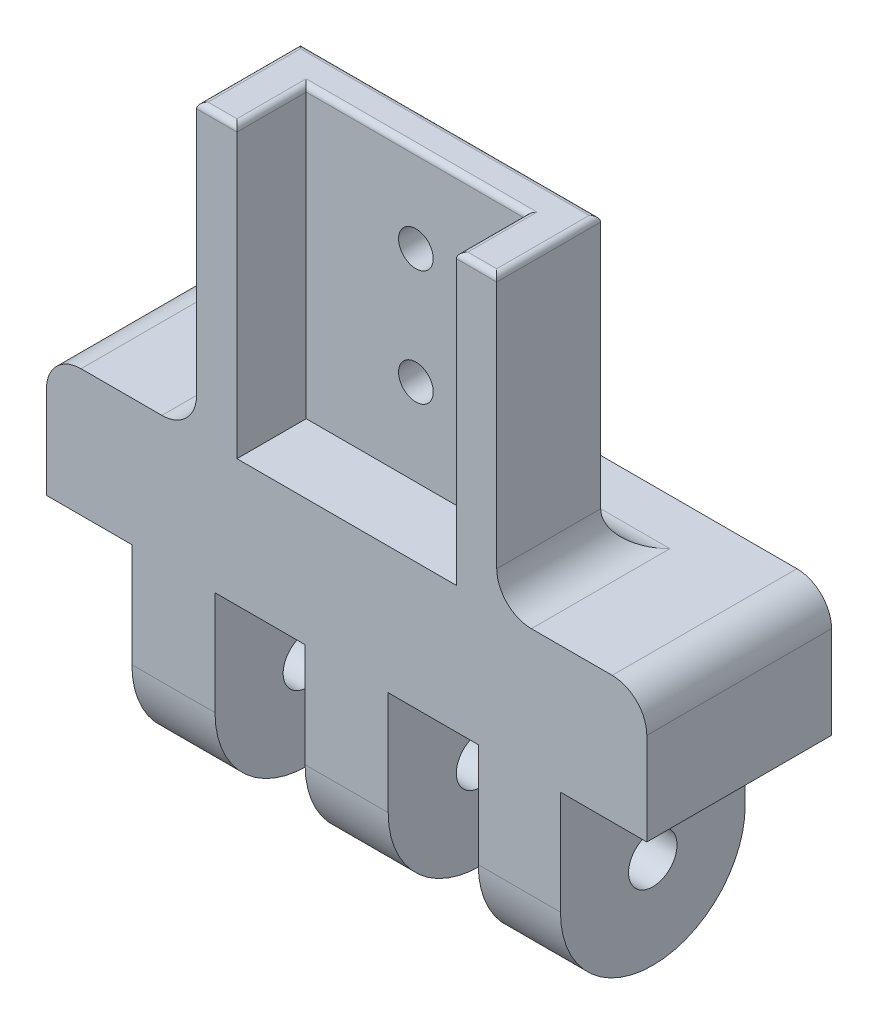
from build123d import *

# Parameters (mm, degrees)
SKETCH2_R           = 2.1
BOSS_EXTRUDE1_DEPTH = 26
SKETCH3_W           = 7.4
SKETCH3_H           = 18
SKETCH3_W_2         = 7.8
SKETCH3_W_3         = 7.481047655
CUT_EXTRUDE1_DEPTH  = 17
SKETCH4_W           = 26
SKETCH4_H           = 9
BOSS_EXTRUDE2_DEPTH = 25
SKETCH5_W           = 19
SKETCH5_H           = 6
CUT_EXTRUDE2_DEPTH  = 25
FILLET1_R           = 3
FILLET2_R           = 3
FILLET3_R           = 0.5
SKETCH6_R           = 1.5
CUT_EXTRUDE3_DEPTH  = 12.5


with BuildPart() as part:
    # Sketch2 → Boss-Extrude1 (new body, symmetric)
    with BuildSketch(Plane(origin=(0, 0, 0), x_dir=(0, 0, -1), z_dir=(1, 0, 0))):
        with BuildLine():
            Line((-8, 0), (-8, 20))
            Line((-8, 20), (8, 20))
            Line((8, 20), (8, 0))
            ThreePointArc((8, 0), (0, -8), (-8, 0))
        make_face()
        Circle(SKETCH2_R, mode=Mode.SUBTRACT)
    extrude(amount=BOSS_EXTRUDE1_DEPTH, both=True)

    # Sketch3 → Cut-Extrude1 (cut, through all)
    with BuildSketch(Plane.XY.offset(8)):
        with Locations((-22.3, 0)):
            Rectangle(SKETCH3_W, SKETCH3_H)
        with Locations((-7.5, 0)):
            Rectangle(SKETCH3_W_2, SKETCH3_H)
        with Locations((7.5, 0)):
            Rectangle(SKETCH3_W_2, SKETCH3_H)
        with Locations((22.259476173, 0)):
            Rectangle(SKETCH3_W_3, SKETCH3_H)
    extrude(amount=-CUT_EXTRUDE1_DEPTH, mode=Mode.SUBTRACT)

    # Sketch4 → Boss-Extrude2 (add)
    with BuildSketch(Plane(origin=(0, 20, 0), x_dir=(1, 0, 0), z_dir=(0, 1, 0))):
        with Locations((0, -3.5)):
            Rectangle(SKETCH4_W, SKETCH4_H)
    extrude(amount=BOSS_EXTRUDE2_DEPTH)

    # Sketch5 → Cut-Extrude2 (cut)
    with BuildSketch(Plane(origin=(0, 45, 0), x_dir=(1, 0, 0), z_dir=(0, 1, 0))):
        with Locations((0, -5)):
            Rectangle(SKETCH5_W, SKETCH5_H)
    extrude(amount=-CUT_EXTRUDE2_DEPTH, mode=Mode.SUBTRACT)

    # Fillet1
    fillet1_edges = [part.edges().sort_by_distance(p)[0] for p in [
        (-13, 20, 3.5),
        (13, 20, 3.5),
        (0, 20, -1),
    ]]
    fillet(fillet1_edges, radius=FILLET1_R)

    # Fillet2
    fillet2_edges = [part.edges().sort_by_distance(p)[0] for p in [
        (26, 20, 0),
        (-26, 20, 0),
    ]]
    fillet(fillet2_edges, radius=FILLET2_R)

    # Fillet3
    fillet3_edges = [part.edges().sort_by_distance(p)[0] for p in [
        (-13, 45, 3.5),
        (-11.25, 45, 8),
        (13, 45, 3.5),
        (0, 45, -1),
        (11.25, 45, 8),
        (9.5, 45, 5),
        (0, 45, 2),
        (-9.5, 45, 5),
    ]]
    fillet(fillet3_edges, radius=FILLET3_R)

    # Sketch6 → Cut-Extrude3 (cut, symmetric)
    with BuildSketch(Plane.XY):
        with Locations((0, 37.5)):
            Circle(SKETCH6_R)
        with Locations((0, 27.5)):
            Circle(SKETCH6_R)
    extrude(amount=CUT_EXTRUDE3_DEPTH, both=True, mode=Mode.SUBTRACT)


solid = part.part
